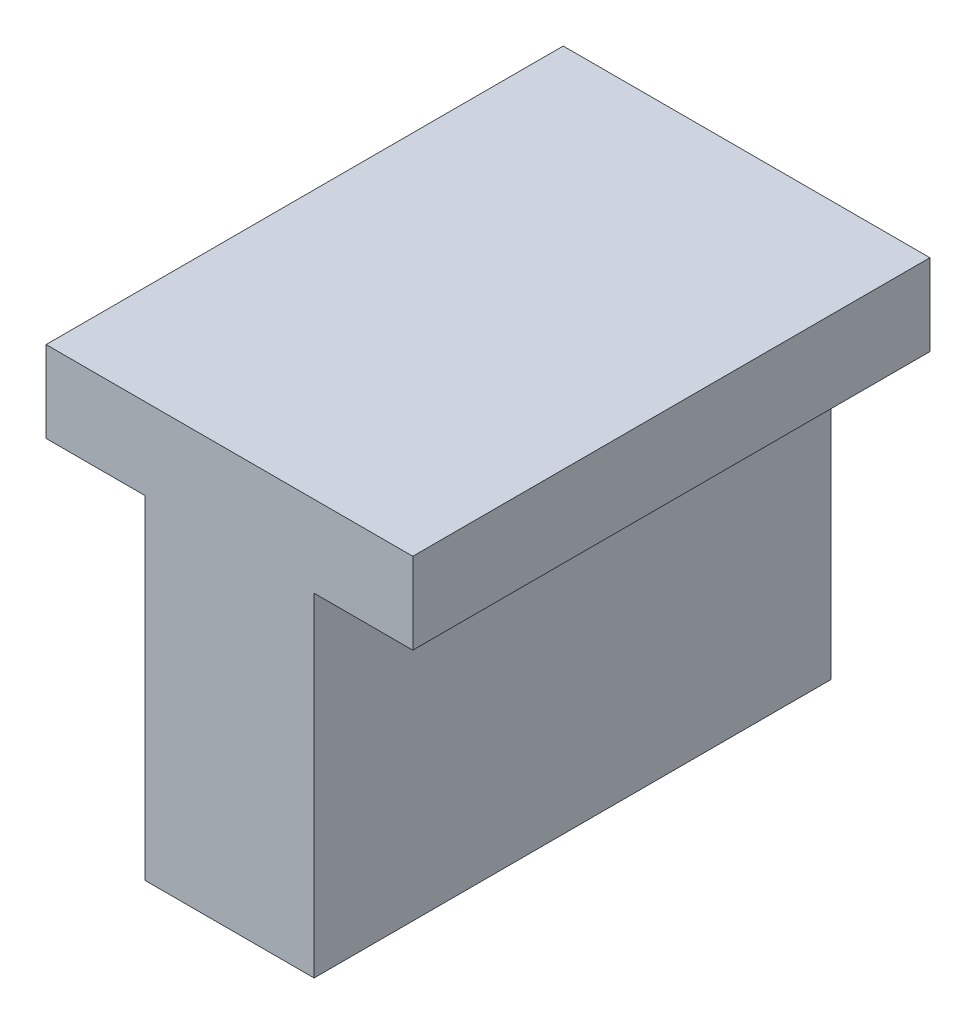
from build123d import *

# Parameters (mm, degrees)
BOSS_EXTRUDE1_DEPTH = 11


with BuildPart() as part:
    # Sketch1 → Boss-Extrude1 (new body)
    with BuildSketch(Plane.XY):
        Polygon((-40.173265573, 24.542711732), (-32.373265573, 24.542711732), (-32.373265573, 22.812711732), (-34.473265573, 22.812711732), (-34.473265573, 15.723691168), (-38.073265573, 15.723691168), (-38.073265573, 22.812711732), (-40.173265573, 22.812711732), align=None)
    extrude(amount=BOSS_EXTRUDE1_DEPTH)


solid = part.part
